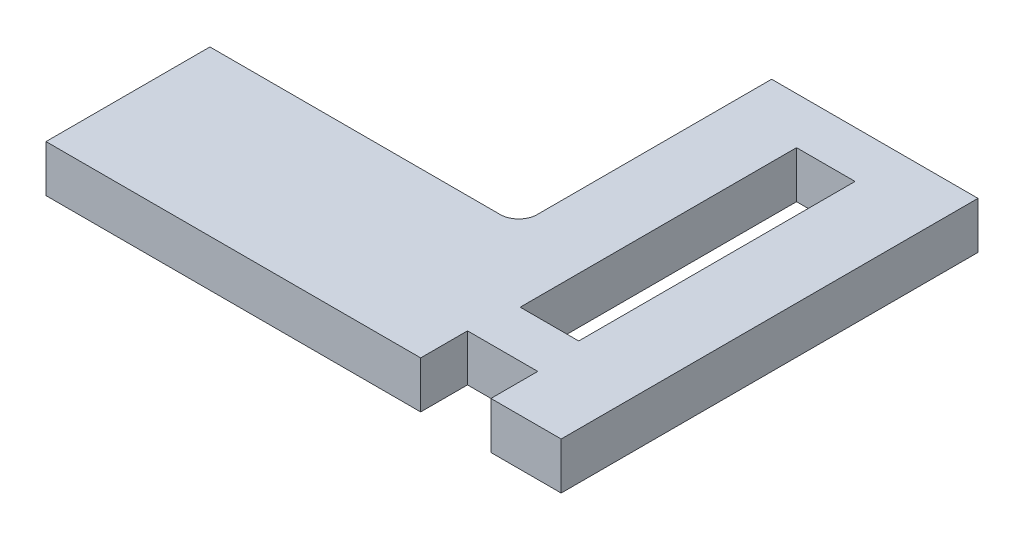
from build123d import *

# Parameters (mm, degrees)
SKETCH1_W           = 31.742721484
SKETCH1_H           = 149.86
BOSS_EXTRUDE1_DEPTH = 25.4


with BuildPart() as part:
    # Sketch1 → Boss-Extrude1 (new body)
    with BuildSketch(Plane(origin=(0, 0, 0), x_dir=(1, 0, 0), z_dir=(0, 1, 0))):
        with BuildLine():
            Line((0, 0), (0, 88.9))
            Line((0, 88.9), (157.48, 88.9))
            ThreePointArc((157.48, 88.9), (164.551067812, 91.828932188), (167.48, 98.9))
            Line((167.48, 98.9), (167.48, 226.06))
            Line((167.48, 226.06), (279.4, 226.06))
            Line((279.4, 226.06), (279.4, 0))
            Line((279.4, 0), (241.3, 0))
            Line((241.3, 0), (241.3, 25.4))
            Line((241.3, 25.4), (203.2, 25.4))
            Line((203.2, 25.4), (203.2, 0))
            Line((203.2, 0), (0, 0))
        make_face()
        with Locations((222.25, 125.73)):
            Rectangle(SKETCH1_W, SKETCH1_H, mode=Mode.SUBTRACT)
    extrude(amount=BOSS_EXTRUDE1_DEPTH)


solid = part.part
